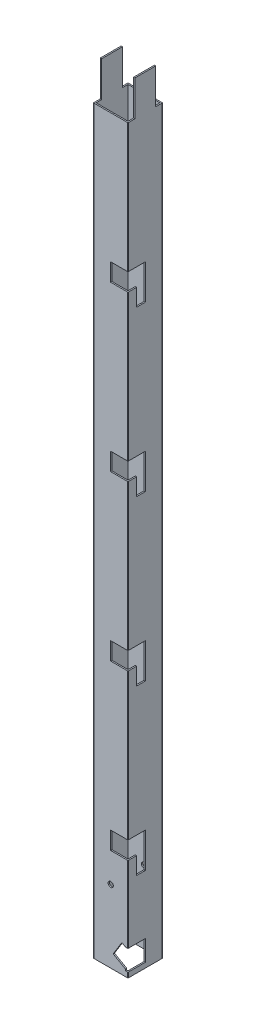
from build123d import *

# Parameters (mm, degrees)
SKETCH1_W           = 37
SKETCH1_H           = 37
BOSS_EXTRUDE1_DEPTH = 899
CUT_EXTRUDE2_DEPTH  = 20
SKETCH4_W           = 8
SKETCH4_H           = 41
CUT_EXTRUDE3_DEPTH  = 901.777997067
SKETCH5_R           = 3.58636949
CUT_EXTRUDE4_DEPTH  = 10
CUT_EXTRUDE5_DEPTH  = 20
SKETCH7_R           = 3
CUT_EXTRUDE6_DEPTH  = 901.777997067


with BuildPart() as part:
    # Sketch1 → Boss-Extrude1 (new body)
    with BuildSketch(Plane(origin=(0, 0, 0), x_dir=(1, 0, 0), z_dir=(0, 1, 0))):
        with BuildLine():
            Line((0.5, 0), (39.5, 0))
            ThreePointArc((39.5, 0), (39.853553391, 0.146446609), (40, 0.5))
            Line((40, 0.5), (40, 39.5))
            ThreePointArc((40, 39.5), (39.853553391, 39.853553391), (39.5, 40))
            Line((39.5, 40), (0.5, 40))
            ThreePointArc((0.5, 40), (0.146446609, 39.853553391), (0, 39.5))
            Line((0, 39.5), (0, 0.5))
            ThreePointArc((0, 0.5), (0.146446609, 0.146446609), (0.5, 0))
        make_face()
        with Locations((20, 20)):
            Rectangle(SKETCH1_W, SKETCH1_H, mode=Mode.SUBTRACT)
    extrude(amount=BOSS_EXTRUDE1_DEPTH)

    # Sketch3 → Cut-Extrude2 (cut)
    with BuildSketch(Plane.XY):
        Polygon((40, 5.907288086), (37, 5.907288086), (37, 7.639845548), (22.874509033, 15.797587142), (32.926772366, 32.098076211), (37, 29.74639714), (40, 29.74639714), (40, 28.014346333), align=None)
    extrude(amount=-CUT_EXTRUDE2_DEPTH, mode=Mode.SUBTRACT)

    # Sketch4 → Cut-Extrude3 (cut, through all)
    with BuildSketch(Plane.ZY):
        with Locations((-4, 878.5)):
            Rectangle(SKETCH4_W, SKETCH4_H)
        with Locations((-36, 878.5)):
            Rectangle(SKETCH4_W, SKETCH4_H)
    extrude(amount=-CUT_EXTRUDE3_DEPTH, mode=Mode.SUBTRACT)

    # Sketch5 → Cut-Extrude4 (cut)
    with BuildSketch(Plane(origin=(0, 0, -40), x_dir=(-1, 0, 0), z_dir=(0, 0, -1))):
        with Locations((-30, 30)):
            Circle(SKETCH5_R)
        with Locations((-30, 15)):
            Circle(SKETCH5_R)
    extrude(amount=-CUT_EXTRUDE4_DEPTH, mode=Mode.SUBTRACT)

    # Sketch6 → Cut-Extrude5 (cut)
    with BuildSketch(Plane(origin=(40, 0, 0), x_dir=(0, 0, -1), z_dir=(1, 0, 0))):
        Polygon((0, 708.5), (20, 708.5), (20, 668), (10, 668), (10, 688), (0, 688), align=None)
        Polygon((0, 518.5), (20, 518.5), (20, 478), (10, 478), (10, 498), (0, 498), align=None)
        Polygon((0, 328.5), (20, 328.5), (20, 288), (10, 288), (10, 308), (0, 308), align=None)
        Polygon((0, 138.5), (20, 138.5), (20, 98), (10, 98), (10, 118), (0, 118), align=None)
    extrude(amount=-CUT_EXTRUDE5_DEPTH, mode=Mode.SUBTRACT)

    # Sketch7 → Cut-Extrude6 (cut, through all)
    with BuildSketch(Plane.XY):
        with Locations((20, 84)):
            Circle(SKETCH7_R)
    extrude(amount=-CUT_EXTRUDE6_DEPTH, mode=Mode.SUBTRACT)


solid = part.part
